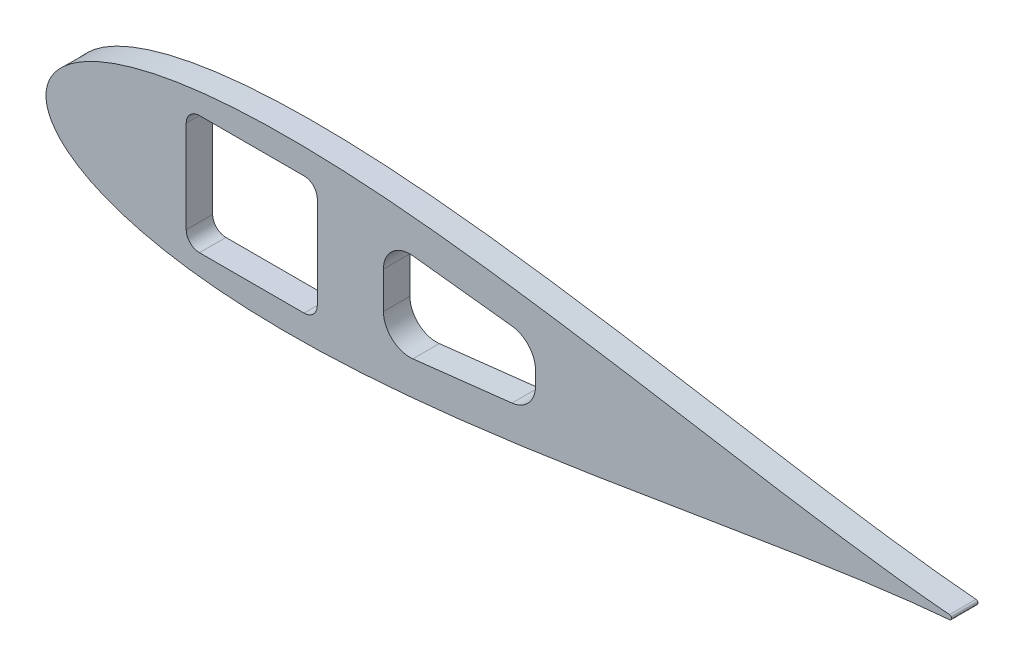
from build123d import *

# Parameters (mm, degrees)
BOSS_EXTRUDE1_DEPTH = 5.4737
SCALE1_SCALE        = 0.27
BOSS_EXTRUDE2_DEPTH = 5.08
SKETCH10_W          = 25.167167629
SKETCH10_H          = 22.8092
CUT_EXTRUDE6_DEPTH  = 6.0800001
FILLET1_R           = 2.54
CUT_EXTRUDE7_DEPTH  = 6.0800001
FILLET2_R           = 5.08


with BuildPart() as part:
    # Sketch2 → Boss-Extrude1 (new body)
    with BuildSketch(Plane.XY):
        with BuildLine():
            add(Edge.make_bspline(
                [(642.510849283, 1.582039112), (641.993392355, 1.625070631), (638.093728429, 1.953546407), (630.413817462, 2.663385493), (619.014124193, 3.849253664), (606.374988512, 5.304428983), (592.543922516, 7.037634907), (577.585454095, 9.050636147), (561.564270734, 11.338919625), (544.549749946, 13.890665375), (526.614143658, 16.687720753), (507.832591566, 19.705111663), (488.282710288, 22.911672601), (468.044367735, 26.27043606), (447.199424328, 29.739007432), (425.831595832, 33.270324121), (404.02631566, 36.813220545), (381.870662856, 40.313266856), (359.453314895, 43.713502532), (336.86454415, 46.955447457), (314.196207315, 49.979843895), (291.541767704, 52.727712704), (268.996310773, 55.141201012), (246.65655865, 57.164603829), (224.620860897, 58.745176641), (202.989192599, 59.8341217), (181.863132616, 60.387506142), (161.345829027, 60.366961324), (141.542033828, 59.739895824), (122.558104573, 58.481758104), (104.502313427, 56.574303932), (87.485018636, 54.008935199), (71.619696083, 50.784752003), (57.023709725, 46.912543066), (43.82045433, 42.41500246), (32.141645239, 37.332204029), (22.129107375, 31.731455339), (13.932423524, 25.726412106), (7.689616489, 19.513207632), (3.463136343, 13.420354421), (1.106333228, 7.923389435), (0.154611582, 3.513796615), (-0.062151598, 0), (0.154611582, -3.513796615), (1.106333228, -7.923389435), (3.463136343, -13.420354421), (7.689616489, -19.513207632), (13.932423524, -25.726412106), (22.129107375, -31.731455339), (32.141645239, -37.332204029), (43.82045433, -42.41500246), (57.023709725, -46.912543066), (71.619696083, -50.784752003), (87.485018636, -54.008935199), (104.502313427, -56.574303932), (122.558104573, -58.481758104), (141.542033828, -59.739895824), (161.345829027, -60.366961324), (181.863132616, -60.387506142), (202.989192599, -59.8341217), (224.620860897, -58.745176641), (246.65655865, -57.164603829), (268.996310773, -55.141201012), (291.541767704, -52.727712704), (314.196207315, -49.979843895), (336.86454415, -46.955447457), (359.453314895, -43.713502532), (381.870662856, -40.313266856), (404.02631566, -36.813220545), (425.831595832, -33.270324121), (447.199424328, -29.739007432), (468.044367735, -26.27043606), (488.282710288, -22.911672601), (507.832591566, -19.705111663), (526.614143658, -16.687720753), (544.549749946, -13.890665375), (561.564270734, -11.338919625), (577.585454095, -9.050636147), (592.543922516, -7.037634907), (606.374988512, -5.304428983), (619.014124193, -3.849253664), (630.413817462, -2.663385493), (638.093728429, -1.953546407), (641.993392355, -1.625070631), (642.510849283, -1.582039112)],
                knots=[0.020157042, 0.020157042, 0.020157042, 0.020157042, 0.021270888, 0.028552555, 0.036780684, 0.045920102, 0.055931764, 0.066772884, 0.07839713, 0.090754827, 0.103793165, 0.117456432, 0.131686226, 0.146421738, 0.161599998, 0.177156133, 0.193023668, 0.209134786, 0.225420633, 0.241811602, 0.258237647, 0.274628557, 0.290914287, 0.307025229, 0.322892517, 0.338448342, 0.353626207, 0.368361232, 0.382590428, 0.396252961, 0.409290412, 0.42164701, 0.433269881, 0.444109249, 0.45411864, 0.463255055, 0.471479114, 0.478755289, 0.485052318, 0.490344026, 0.494609833, 0.497833231, 0.5, 0.502166769, 0.505390167, 0.509655974, 0.514947682, 0.521244711, 0.528520886, 0.536744945, 0.54588136, 0.555890751, 0.566730119, 0.57835299, 0.590709588, 0.603747039, 0.617409572, 0.631638768, 0.646373793, 0.661551658, 0.677107483, 0.692974771, 0.709085713, 0.725371443, 0.741762353, 0.758188398, 0.774579367, 0.790865214, 0.806976332, 0.822843867, 0.838400002, 0.853578262, 0.868313774, 0.882543568, 0.896206835, 0.909245173, 0.92160287, 0.933227116, 0.944068236, 0.954079898, 0.963219316, 0.971447445, 0.978729112, 0.979842958, 0.979842958, 0.979842958, 0.979842958], degree=3))
            ThreePointArc((642.510849283, -1.582039112), (643.966787522, 0), (642.510849283, 1.582039112))
        make_face()
    extrude(amount=BOSS_EXTRUDE1_DEPTH)


with BuildPart() as part_1:
    # Scale1: scaled about (0, 0, 0)
    add(part.part.scale(SCALE1_SCALE))

    # Sketch11 → Boss-Extrude2 (add)
    with BuildSketch(Plane(origin=(0, 0, 0), x_dir=(-1, 0, 0), z_dir=(0, 0, -1))):
        with BuildLine():
            ThreePointArc((-173.477929306, 0.42715056), (-173.871032631, 0), (-173.477929306, -0.42715056))
            add(Edge.make_bspline(
                [(-173.477929306, -0.42715056), (-173.338215936, -0.43876907), (-172.285306676, -0.52745753), (-170.211730715, -0.719114083), (-167.133813532, -1.039298489), (-163.721246898, -1.432195826), (-159.986859079, -1.900161425), (-155.948072606, -2.44367176), (-151.622353098, -3.061508299), (-147.028432485, -3.750479651), (-142.185818788, -4.505684603), (-137.114799723, -5.320380149), (-131.836331778, -6.186151602), (-126.371979288, -7.093017736), (-120.743844569, -8.029532007), (-114.974530875, -8.982987513), (-109.087105228, -9.939569547), (-103.105078971, -10.884582051), (-97.052395022, -11.802645684), (-90.953426921, -12.677970813), (-84.832975975, -13.494557852), (-78.71627728, -14.23648243), (-72.629003909, -14.888124273), (-66.597270835, -15.434443034), (-60.647632442, -15.861197693), (-54.807082002, -16.155212859), (-49.103045806, -16.304626658), (-43.563373837, -16.299079558), (-38.216349134, -16.129771873), (-33.090688235, -15.790074688), (-28.215624625, -15.275062062), (-23.620955032, -14.582412504), (-19.337317942, -13.711883041), (-15.396401626, -12.666386628), (-11.831522669, -11.452050664), (-8.678244214, -10.079695088), (-5.974858991, -8.567492941), (-3.761754351, -6.946131269), (-2.076196452, -5.268566061), (-0.935046813, -3.623495694), (-0.298709971, -2.139315147), (-0.041745127, -0.948725086), (0.016780931, 0), (-0.041745127, 0.948725086), (-0.298709971, 2.139315147), (-0.935046813, 3.623495694), (-2.076196452, 5.268566061), (-3.761754351, 6.946131269), (-5.974858991, 8.567492941), (-8.678244214, 10.079695088), (-11.831522669, 11.452050664), (-15.396401626, 12.666386628), (-19.337317942, 13.711883041), (-23.620955032, 14.582412504), (-28.215624625, 15.275062062), (-33.090688235, 15.790074688), (-38.216349134, 16.129771873), (-43.563373837, 16.299079558), (-49.103045806, 16.304626658), (-54.807082002, 16.155212859), (-60.647632442, 15.861197693), (-66.597270835, 15.434443034), (-72.629003909, 14.888124273), (-78.71627728, 14.23648243), (-84.832975975, 13.494557852), (-90.953426921, 12.677970813), (-97.052395022, 11.802645684), (-103.105078971, 10.884582051), (-109.087105228, 9.939569547), (-114.974530875, 8.982987513), (-120.743844569, 8.029532007), (-126.371979288, 7.093017736), (-131.836331778, 6.186151602), (-137.114799723, 5.320380149), (-142.185818788, 4.505684603), (-147.028432485, 3.750479651), (-151.622353098, 3.061508299), (-155.948072606, 2.44367176), (-159.986859079, 1.900161425), (-163.721246898, 1.432195826), (-167.133813532, 1.039298489), (-170.211730715, 0.719114083), (-172.285306676, 0.52745753), (-173.338215936, 0.43876907), (-173.477929306, 0.42715056)],
                knots=[0.020157042, 0.020157042, 0.020157042, 0.020157042, 0.021270888, 0.028552555, 0.036780684, 0.045920102, 0.055931764, 0.066772884, 0.07839713, 0.090754827, 0.103793165, 0.117456432, 0.131686226, 0.146421738, 0.161599998, 0.177156133, 0.193023668, 0.209134786, 0.225420633, 0.241811602, 0.258237647, 0.274628557, 0.290914287, 0.307025229, 0.322892517, 0.338448342, 0.353626207, 0.368361232, 0.382590428, 0.396252961, 0.409290412, 0.42164701, 0.433269881, 0.444109249, 0.45411864, 0.463255055, 0.471479114, 0.478755289, 0.485052318, 0.490344026, 0.494609833, 0.497833231, 0.5, 0.502166769, 0.505390167, 0.509655974, 0.514947682, 0.521244711, 0.528520886, 0.536744945, 0.54588136, 0.555890751, 0.566730119, 0.57835299, 0.590709588, 0.603747039, 0.617409572, 0.631638768, 0.646373793, 0.661551658, 0.677107483, 0.692974771, 0.709085713, 0.725371443, 0.741762353, 0.758188398, 0.774579367, 0.790865214, 0.806976332, 0.822843867, 0.838400002, 0.853578262, 0.868313774, 0.882543568, 0.896206835, 0.909245173, 0.92160287, 0.933227116, 0.944068236, 0.954079898, 0.963219316, 0.971447445, 0.978729112, 0.979842958, 0.979842958, 0.979842958, 0.979842958], degree=3))
        make_face()
    extrude(amount=-BOSS_EXTRUDE2_DEPTH)

    # Sketch10 → Cut-Extrude6 (cut, through all)
    with BuildSketch(Plane.XY):
        with Locations((39.507583815, 0)):
            Rectangle(SKETCH10_W, SKETCH10_H)
    extrude(amount=CUT_EXTRUDE6_DEPTH, mode=Mode.SUBTRACT)

    # Fillet1
    fillet1_edges = [part_1.edges().sort_by_distance(p)[0] for p in [
        (52.091167629, -11.4046, 2.54),
        (52.091167629, 11.4046, 2.54),
        (26.924, 11.4046, 2.54),
        (26.924, -11.4046, 2.54),
    ]]
    fillet(fillet1_edges, radius=FILLET1_R)

    # Sketch12 → Cut-Extrude7 (cut, through all)
    with BuildSketch(Plane(origin=(0, 0, 0), x_dir=(-1, 0, 0), z_dir=(0, 0, -1))):
        Polygon((-64.791167629, -9.207005666), (-64.791167629, 9.207005666), (-93.978207942, 5.891518956), (-93.978207942, -5.891518956), align=None)
    extrude(amount=-CUT_EXTRUDE7_DEPTH, mode=Mode.SUBTRACT)

    # Fillet2
    fillet2_edges = [part_1.edges().sort_by_distance(p)[0] for p in [
        (64.791167629, -9.207005666, 2.54),
        (93.978207942, -5.891518956, 2.54),
        (93.978207942, 5.891518956, 2.54),
        (64.791167629, 9.207005666, 2.54),
    ]]
    fillet(fillet2_edges, radius=FILLET2_R)


solid = part_1.part
